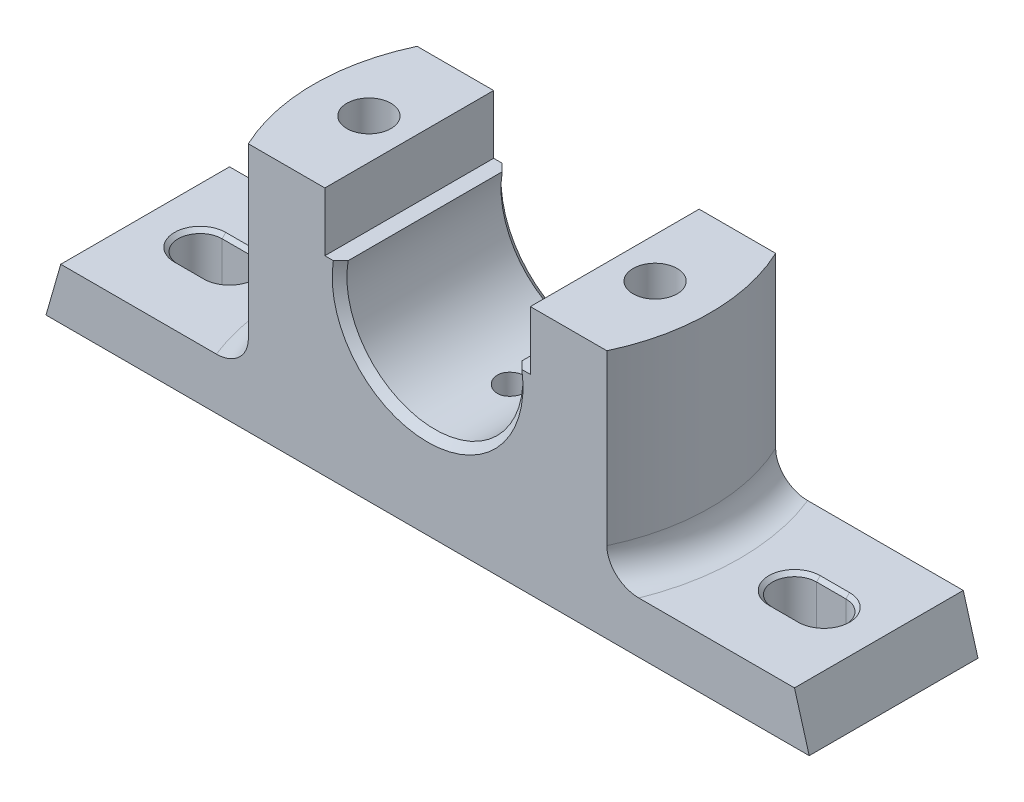
from build123d import *

# Parameters (mm, degrees)
BOSS_EXTRUDE1_DEPTH = 23
BOSS_EXTRUDE2_DEPTH = 54
CUT_EXTRUDE1_DEPTH  = 47
SKETCH4_R           = 6
CUT_EXTRUDE2_DEPTH  = 69
SKETCH5_W           = 28
SKETCH5_H           = 28
CUT_EXTRUDE3_DEPTH  = 8
CUT_EXTRUDE4_DEPTH  = 15
SKETCH7_R           = 4
CUT_EXTRUDE5_DEPTH  = 54
FILLET1_R           = 8
CHAMFER1_SIZE       = 2
CHAMFER2_SIZE       = 1


with BuildPart() as part:
    # Sketch1 → Boss-Extrude1 (new body, symmetric)
    with BuildSketch(Plane.XY):
        Polygon((-104, 0), (104, 0), (99.985564599, 14), (-99.985564599, 14), align=None)
    extrude(amount=BOSS_EXTRUDE1_DEPTH, both=True)

    # Sketch2 → Boss-Extrude2 (add)
    with BuildSketch(Plane(origin=(0, 14, 0), x_dir=(1, 0, 0), z_dir=(0, 1, 0))):
        with BuildLine():
            Line((48.856934001, 23), (-48.856934001, 23))
            ThreePointArc((-48.856934001, 23), (-54, 0), (-48.856934001, -23))
            Line((-48.856934001, -23), (48.856934001, -23))
            ThreePointArc((48.856934001, -23), (54, 0), (48.856934001, 23))
        make_face()
    extrude(amount=BOSS_EXTRUDE2_DEPTH)

    # Sketch3 → Cut-Extrude1 (cut, through all)
    with BuildSketch(Plane.XY.offset(23)):
        with BuildLine():
            Line((-28, 68), (-28, 52))
            Line((-28, 52), (-23.664319132, 52))
            ThreePointArc((-23.664319132, 52), (0, 24), (23.664319132, 52))
            Line((23.664319132, 52), (28, 52))
            Line((28, 52), (28, 68))
            Line((28, 68), (-28, 68))
        make_face()
    extrude(amount=-CUT_EXTRUDE1_DEPTH, mode=Mode.SUBTRACT)

    # Sketch4 → Cut-Extrude2 (cut, through all)
    with BuildSketch(Plane(origin=(0, 68, 0), x_dir=(1, 0, 0), z_dir=(0, 1, 0))):
        with Locations(Location((-39, 0, 0), (0, 0, 270))):  # turned: the seam where the file's is
            Circle(SKETCH4_R)
        with Locations(Location((39, 0, 0), (0, 0, 270))):  # turned: the seam where the file's is
            Circle(SKETCH4_R)
    extrude(amount=-CUT_EXTRUDE2_DEPTH, mode=Mode.SUBTRACT)

    # Sketch5 → Cut-Extrude3 (cut)
    with BuildSketch(Plane.XZ):
        with Locations((-39, 0)):
            Rectangle(SKETCH5_W, SKETCH5_H)
        with Locations((39, 0)):
            Rectangle(SKETCH5_W, SKETCH5_H)
    extrude(amount=-CUT_EXTRUDE3_DEPTH, mode=Mode.SUBTRACT)

    # Sketch6 → Cut-Extrude4 (cut, through all)
    with BuildSketch(Plane(origin=(0, 14, 0), x_dir=(1, 0, 0), z_dir=(0, 1, 0))):
        with BuildLine():
            Line((-85, 6), (-77, 6))
            ThreePointArc((-77, 6), (-71, 0), (-77, -6))
            Line((-77, -6), (-85, -6))
            ThreePointArc((-85, -6), (-91, 0), (-85, 6))
        make_face()
    cut_extrude4 = extrude(amount=-CUT_EXTRUDE4_DEPTH, mode=Mode.SUBTRACT)

    # Mirror1: Cut-Extrude4 across plane
    add(cut_extrude4.mirror(Plane(origin=(0, 0, 0), x_dir=(0, 0, 1), z_dir=(1, 0, 0))), mode=Mode.SUBTRACT)

    # Sketch7 → Cut-Extrude5 (cut)
    with BuildSketch(Plane(origin=(0, 68, 0), x_dir=(1, 0, 0), z_dir=(0, 1, 0))):
        with Locations(Location((0, 0, 0), (0, 0, 270))):  # turned: the seam where the file's is
            Circle(SKETCH7_R)
    extrude(amount=-CUT_EXTRUDE5_DEPTH, mode=Mode.SUBTRACT)

    # Fillet1
    fillet1_edges = [part.edges().sort_by_distance(p)[0] for p in [
        (54, 14, 0),
        (-54, 14, 0),
    ]]
    fillet(fillet1_edges, radius=FILLET1_R)

    # Chamfer1
    chamfer1_edges = [part.edges().sort_by_distance(p)[0] for p in [
        (0, 24, -23),
        (0, 24, 23),
    ]]
    chamfer(chamfer1_edges, length=CHAMFER1_SIZE)

    # Chamfer2
    chamfer2_edges = [part.edges().sort_by_distance(p)[0] for p in [
        (91, 14, 0),
        (81, 14, 6),
        (71, 14, 0),
        (81, 14, -6),
        (-91, 14, 0),
        (-81, 14, 6),
        (-71, 14, 0),
        (-81, 14, -6),
    ]]
    chamfer(chamfer2_edges, length=CHAMFER2_SIZE)


solid = part.part
